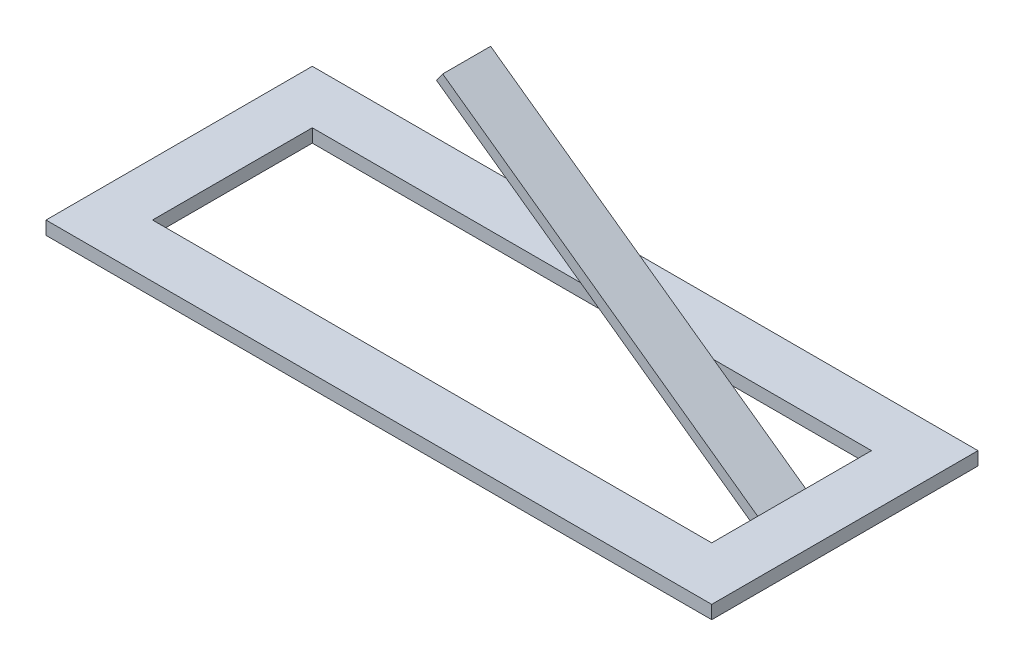
from build123d import *

# Parameters (mm, degrees)
SKETCH1_W           = 20
SKETCH1_H           = 60
BOSS_EXTRUDE2_DEPTH = 10
BOSS_EXTRUDE3_DEPTH = 36
SKETCH3_W           = 140
SKETCH3_H           = 140
CUT_EXTRUDE1_DEPTH  = 18
SKETCH4_W           = 8.585490735
SKETCH4_H           = 18
CUT_EXTRUDE3_DEPTH  = 46
SKETCH5_W           = 250
SKETCH5_H           = 5
CUT_EXTRUDE4_DEPTH  = 137


with BuildPart() as part:
    # Sketch1 → Boss-Extrude2 (new body)
    with BuildSketch(Plane(origin=(0, 0, 0), x_dir=(1, 0, 0), z_dir=(0, 1, 0))):
        Polygon((166.222222222, 60), (146.222222222, 60), (-63.777777778, 60), (-83.777777778, 60), (-83.777777778, 80), (166.222222222, 80), align=None)
        with Locations((156.222222222, 30)):
            Rectangle(SKETCH1_W, SKETCH1_H)
        Polygon((166.222222222, 0), (146.222222222, 0), (-63.777777778, 0), (-83.777777778, 0), (-83.777777778, -20), (166.222222222, -20), align=None)
        with Locations((-73.777777778, 30)):
            Rectangle(SKETCH1_W, SKETCH1_H)
    extrude(amount=BOSS_EXTRUDE2_DEPTH)

    # Sketch2 → Boss-Extrude3 (add)
    with BuildSketch(Plane.XY):
        Polygon((155.307951765, 2.266232377), (27.198414629, 93.999150061), (24.869662654, 90.746933242), (148.437318839, 2.266232377), align=None)
    extrude(amount=-BOSS_EXTRUDE3_DEPTH)

    # Sketch3 → Cut-Extrude1 (cut)
    with BuildSketch(Plane.XY):
        with Locations((82.194738609, 80)):
            Rectangle(SKETCH3_W, SKETCH3_H)
    extrude(amount=-CUT_EXTRUDE1_DEPTH, mode=Mode.SUBTRACT)

    # Sketch4 → Cut-Extrude3 (cut)
    with BuildSketch(Plane(origin=(0, 10, 0), x_dir=(1, 0, 0), z_dir=(0, 1, 0))):
        with Locations((141.929476855, 9)):
            Rectangle(SKETCH4_W, SKETCH4_H)
    extrude(amount=-CUT_EXTRUDE3_DEPTH, mode=Mode.SUBTRACT)

    # Sketch5 → Cut-Extrude4 (cut)
    with BuildSketch(Plane.XY.offset(20)):
        with Locations((41.222222222, 2.5)):
            Rectangle(SKETCH5_W, SKETCH5_H)
    extrude(amount=-CUT_EXTRUDE4_DEPTH, mode=Mode.SUBTRACT)


solid = part.part
